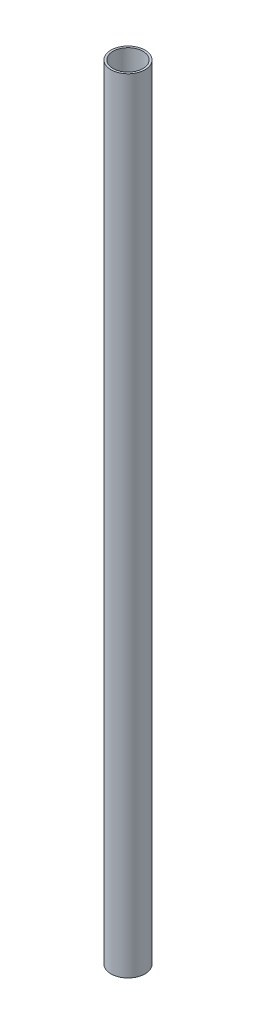
from build123d import *

# Parameters (mm, degrees)
SKETCH1_R           = 12.7
SKETCH1_R_2         = 11.176
BOSS_EXTRUDE1_DEPTH = 584.2


with BuildPart() as part:
    # Sketch1 → Boss-Extrude1 (new body)
    with BuildSketch(Plane(origin=(0, 0, 0), x_dir=(1, 0, 0), z_dir=(0, 1, 0))):
        Circle(SKETCH1_R)
        Circle(SKETCH1_R_2, mode=Mode.SUBTRACT)
    extrude(amount=BOSS_EXTRUDE1_DEPTH)


solid = part.part
